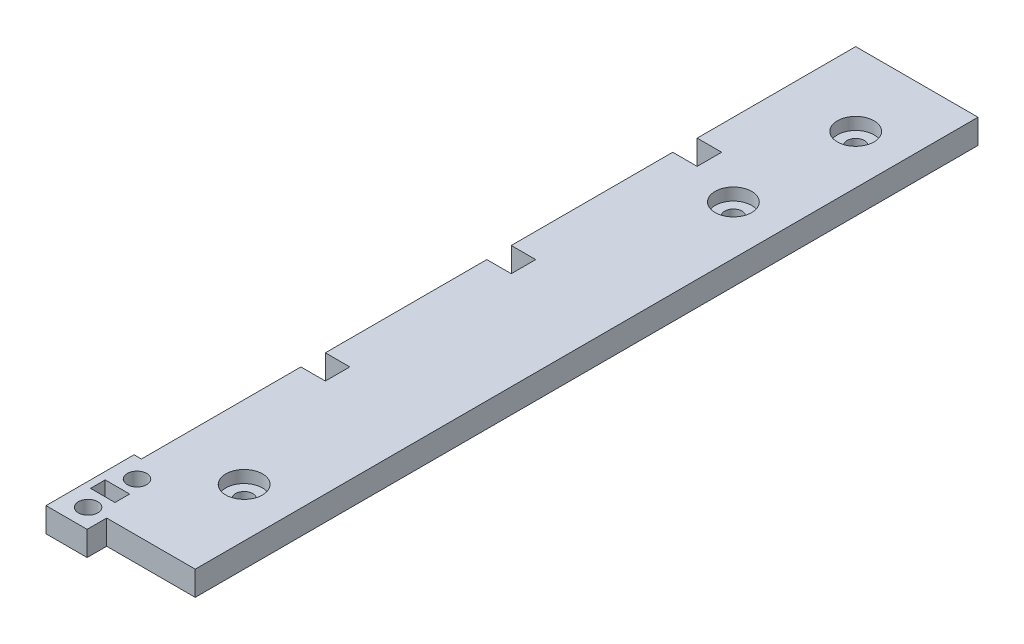
from build123d import *

# Parameters (mm, degrees)
BOSS_EXTRUDE1_DEPTH                                 = 6.35
SKETCH2_W                                           = 6.35
SKETCH2_H                                           = 6.35
CUT_EXTRUDE1_DEPTH                                  = 7.35
F_8_0_199_DIAMETER_HOLE1_D                          = 5.0546
SKETCH5_W                                           = 6.35
SKETCH5_H                                           = 3.81
CUT_EXTRUDE2_DEPTH                                  = 7.35
CBORE_FOR_8_BINDING_HEAD_MACHINE_SCREW1_D           = 4.4958
CBORE_FOR_8_BINDING_HEAD_MACHINE_SCREW1_CBORE_D     = 9.525
CBORE_FOR_8_BINDING_HEAD_MACHINE_SCREW1_CBORE_DEPTH = 3.175


with BuildPart() as part:
    # Sketch1 → Boss-Extrude1 (new body)
    with BuildSketch(Plane(origin=(0, 0, 0), x_dir=(1, 0, 0), z_dir=(0, 1, 0))):
        Polygon((8.763, -10.331391255), (8.763, -15.411391255), (-1.905, -15.411391255), (-1.905, 7.448608745), (0, 7.448608745), (0, 192.868608745), (31.75, 192.868608745), (31.75, -10.331391255), align=None)
    extrude(amount=BOSS_EXTRUDE1_DEPTH)

    # Sketch2 → Cut-Extrude1 (cut, through all)
    with BuildSketch(Plane(origin=(0, 6.35, 0), x_dir=(1, 0, 0), z_dir=(0, 1, 0))):
        with Locations((3.175, 52.025608745)):
            Rectangle(SKETCH2_W, SKETCH2_H)
        with Locations((3.175, 100.285608745)):
            Rectangle(SKETCH2_W, SKETCH2_H)
        with Locations((3.175, 148.545608745)):
            Rectangle(SKETCH2_W, SKETCH2_H)
    extrude(amount=-CUT_EXTRUDE1_DEPTH, mode=Mode.SUBTRACT)

    # #8 (0.199) Diameter Hole1 (through all)
    with Locations(Plane(origin=(0, 6.35, 0), x_dir=(1, 0, 0), z_dir=(0, 1, 0))):
        with Locations((3.937, 2.368608745), (3.937, -10.331391255)):
            Hole(F_8_0_199_DIAMETER_HOLE1_D / 2)

    # Sketch5 → Cut-Extrude2 (cut, through all)
    with BuildSketch(Plane(origin=(0, 6.35, 0), x_dir=(1, 0, 0), z_dir=(0, 1, 0))):
        with Locations((3.175, -3.854391255)):
            Rectangle(SKETCH5_W, SKETCH5_H)
    extrude(amount=-CUT_EXTRUDE2_DEPTH, mode=Mode.SUBTRACT)

    # CBORE for #8 Binding Head Machine Screw1 (through all)
    with Locations(Plane(origin=(0, 6.35, 0), x_dir=(1, 0, 0), z_dir=(0, 1, 0))):
        with Locations((19.05, 173.818608745), (19.05, 142.068608745), (19.05, 15.068608745)):
            CounterBoreHole(CBORE_FOR_8_BINDING_HEAD_MACHINE_SCREW1_D / 2, CBORE_FOR_8_BINDING_HEAD_MACHINE_SCREW1_CBORE_D / 2, CBORE_FOR_8_BINDING_HEAD_MACHINE_SCREW1_CBORE_DEPTH)


solid = part.part
